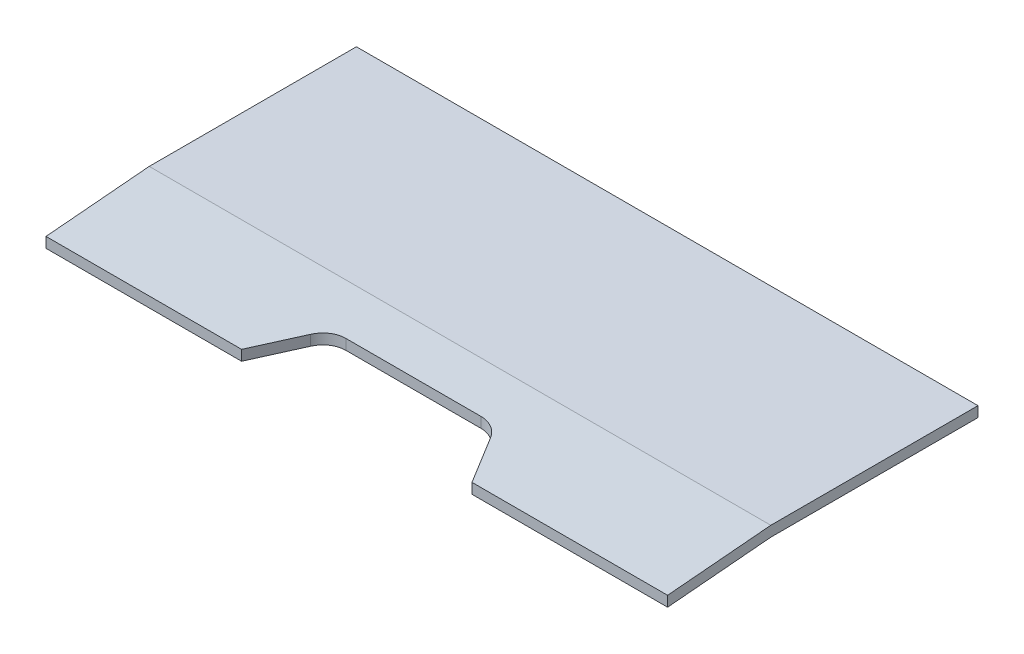
from build123d import *

# Parameters (mm, degrees)
EXTRUDE_1_DEPTH     = 1200
CUT_EXTRUDE_1_DEPTH = 38.43114855


with BuildPart() as part:
    # Эскиз2 → Бобышка-Вытянуть1 (new body)
    with BuildSketch(Plane(origin=(0, 0, 0), x_dir=(0, 0, -1), z_dir=(1, 0, 0))):
        Polygon((0, 20), (0, 0), (-400, 0), (-599.238939618, -17.43114855), (-599.238939618, 2.56885145), (-400, 20), align=None)
    extrude(amount=-EXTRUDE_1_DEPTH)

    # Эскиз3 → Вырез-Вытянуть1 (cut, through all)
    with BuildSketch(Plane(origin=(0, 20, 0), x_dir=(1, 0, 0), z_dir=(0, 1, 0))):
        with BuildLine():
            Line((-822.385668675, -599.238939618), (-377.614331325, -599.238939618))
            Line((-377.614331325, -599.238939618), (-426.451140145, -514.835069456))
            ThreePointArc((-426.451140145, -514.835069456), (-444.74923451, -496.562846761), (-469.728809412, -489.875902964))
            Line((-469.728809412, -489.875902964), (-730.271190588, -489.875902964))
            ThreePointArc((-730.271190588, -489.875902964), (-755.25076549, -496.562846761), (-773.548859855, -514.835069456))
            Line((-773.548859855, -514.835069456), (-822.385668675, -599.238939618))
        make_face()
    extrude(amount=-CUT_EXTRUDE_1_DEPTH, mode=Mode.SUBTRACT)


solid = part.part
